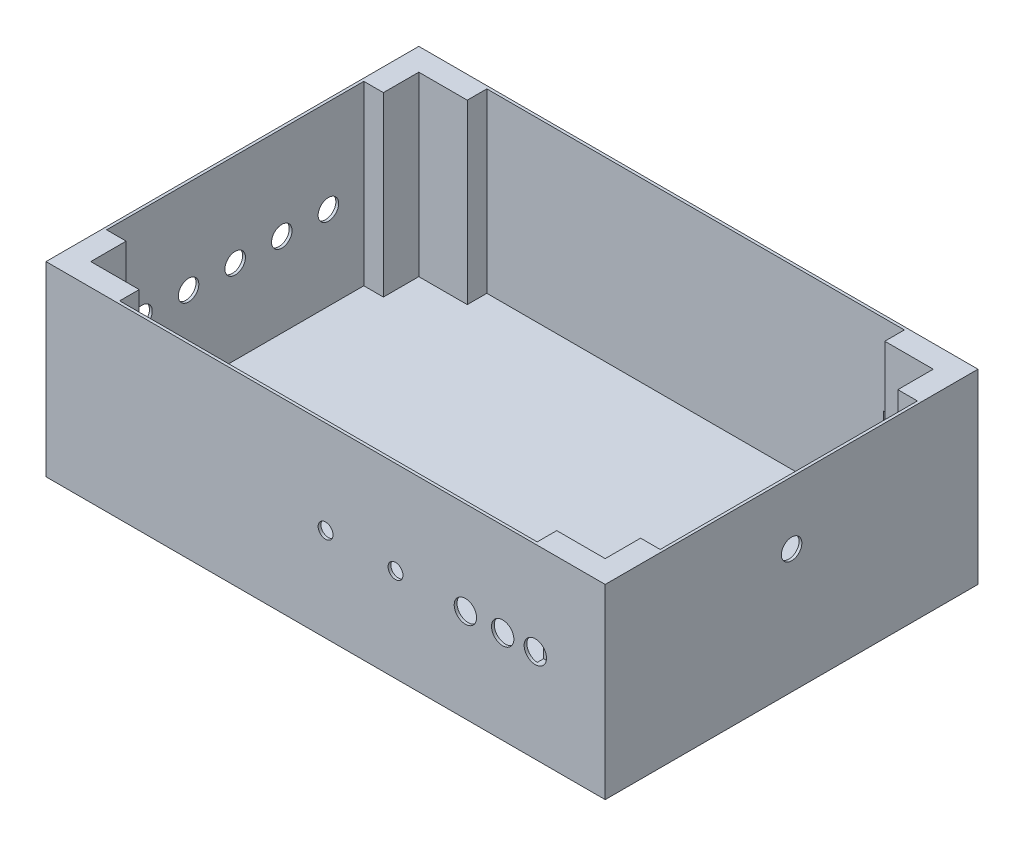
from build123d import *

# Parameters (mm, degrees)
SKETCH1_W           = 600
SKETCH1_H           = 400
BOSS_EXTRUDE1_DEPTH = 200
CUT_EXTRUDE1_DEPTH  = 190
SKETCH3_R           = 11
CUT_EXTRUDE2_DEPTH  = 10
SKETCH4_R           = 12
SKETCH4_R_2         = 8
CUT_EXTRUDE3_DEPTH  = 10
SKETCH5_W           = 47
SKETCH5_H           = 27
CUT_EXTRUDE4_DEPTH  = 10
SKETCH6_R           = 11
CUT_EXTRUDE5_DEPTH  = 10


with BuildPart() as part:
    # Sketch1 → Boss-Extrude1 (new body)
    with BuildSketch(Plane(origin=(0, 0, 0), x_dir=(1, 0, 0), z_dir=(0, 1, 0))):
        Rectangle(SKETCH1_W, SKETCH1_H)
    extrude(amount=BOSS_EXTRUDE1_DEPTH)

    # Sketch2 → Cut-Extrude1 (cut)
    with BuildSketch(Plane(origin=(0, 200, 0), x_dir=(1, 0, 0), z_dir=(0, 1, 0))):
        Polygon((-224, -197), (224, -197), (224, -176), (276, -176), (276, -138), (297, -138), (297, 138), (276, 138), (276, 176), (224, 176), (224, 197), (-224, 197), (-224, 176), (-276, 176), (-276, 138), (-297, 138), (-297, -138), (-276, -138), (-276, -176), (-224, -176), align=None)
    extrude(amount=-CUT_EXTRUDE1_DEPTH, mode=Mode.SUBTRACT)

    # Sketch3 → Cut-Extrude2 (cut)
    with BuildSketch(Plane.ZY.offset(300)):
        with Locations((-100, 100)):
            Circle(SKETCH3_R)
        with Locations((-50, 100)):
            Circle(SKETCH3_R)
        with Locations((50, 100)):
            Circle(SKETCH3_R)
        with Locations((100, 100)):
            Circle(SKETCH3_R)
        with Locations((0, 100)):
            Circle(SKETCH3_R)
    extrude(amount=-CUT_EXTRUDE2_DEPTH, mode=Mode.SUBTRACT)

    # Sketch4 → Cut-Extrude3 (cut)
    with BuildSketch(Plane.XY.offset(200)):
        with Locations((150, 100)):
            Circle(SKETCH4_R)
        with Locations((75, 100)):
            Circle(SKETCH4_R_2)
        with Locations((225, 100)):
            Circle(SKETCH4_R)
        with Locations((0, 100)):
            Circle(SKETCH4_R_2)
        with Locations((190, 100)):
            Circle(SKETCH4_R)
    extrude(amount=-CUT_EXTRUDE3_DEPTH, mode=Mode.SUBTRACT)

    # Sketch5 → Cut-Extrude4 (cut)
    with BuildSketch(Plane(origin=(0, 0, -200), x_dir=(-1, 0, 0), z_dir=(0, 0, -1))):
        with Locations((-225, 100)):
            Rectangle(SKETCH5_W, SKETCH5_H)
    extrude(amount=-CUT_EXTRUDE4_DEPTH, mode=Mode.SUBTRACT)

    # Sketch6 → Cut-Extrude5 (cut)
    with BuildSketch(Plane(origin=(300, 0, 0), x_dir=(0, 0, -1), z_dir=(1, 0, 0))):
        with Locations((0, 133)):
            Circle(SKETCH6_R)
    extrude(amount=-CUT_EXTRUDE5_DEPTH, mode=Mode.SUBTRACT)


solid = part.part
